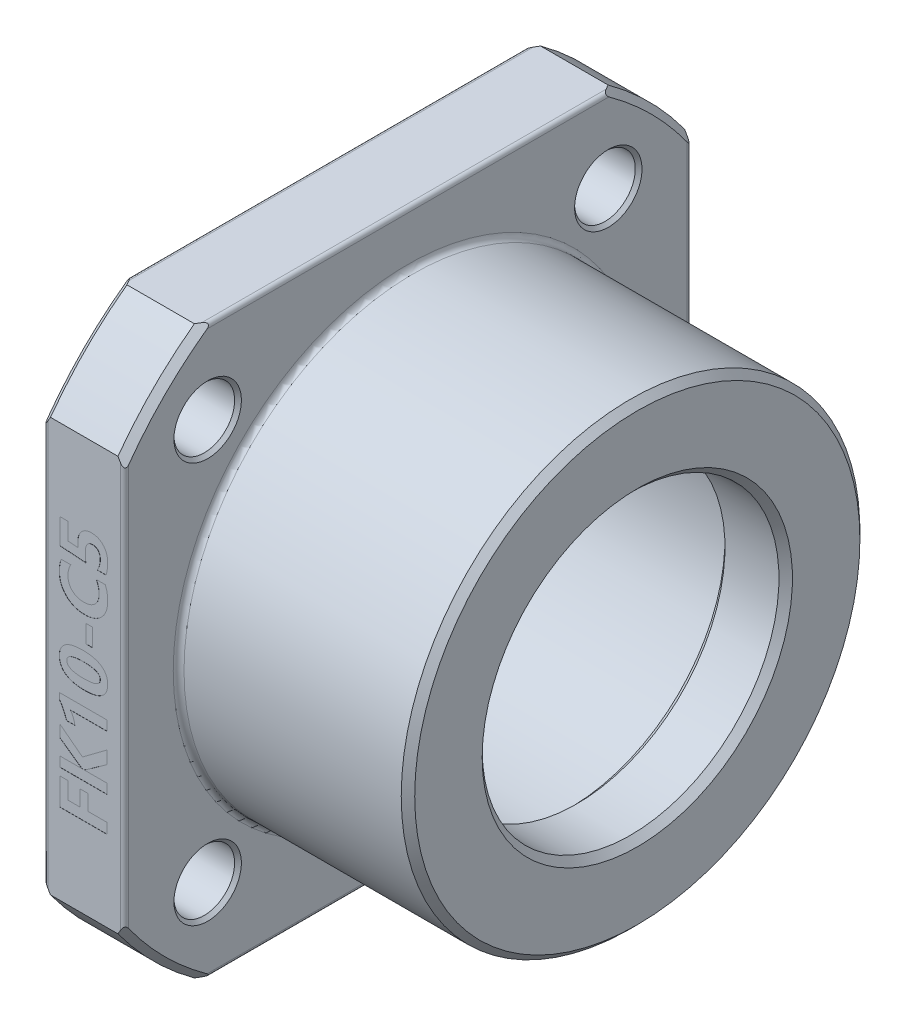
from build123d import *

# Parameters (mm, degrees)
CUT_EXTRUDE_1_REACH              = 25
HOLE_WIZARD_4_5_4_5_1_AT_2_COUNT = 2
HOLE_WIZARD_4_5_4_5_1_AT_2_PITCH = 29.69848481
HOLE_WIZARD_4_5_4_5_1_AT_3_COUNT = 2
HOLE_WIZARD_4_5_4_5_1_AT_3_PITCH = 42
HOLE_WIZARD_4_5_4_5_1_AT_4_COUNT = 2
HOLE_WIZARD_4_5_4_5_1_AT_4_PITCH = 29.69848481
M4X0_71_D                        = 3.3
M4X0_71_DEPTH                    = 5
M4X0_71_CSINK_D                  = 4.2
M4X0_71_CSINK_ANGLE              = 90
M4X0_71_TIP                      = 0.991420021
FILLET_1_R                       = 0.3
SKETCH_7_W                       = 0.512195122
SKETCH_7_H                       = 1.323170731
CUT_EXTRUDE_2_DEPTH              = 0.01


with BuildPart() as part:
    # Эскиз1 → Повернуть1 (revolve)
    with BuildSketch(Plane.XY):
        with BuildLine():
            Line((22.5, 11), (18.5, 11))
            Line((18.5, 11), (18, 11.5))
            Line((18, 11.5), (18, 12.6))
            ThreePointArc((18, 12.6), (17.882842712, 12.882842712), (17.6, 13))
            Line((17.6, 13), (0.5, 13))
            Line((0.5, 13), (0, 13.5))
            Line((0, 13.5), (0, 25.5))
            Line((0, 25.5), (0.5, 26))
            Line((0.5, 26), (5.5, 26))
            Line((5.5, 26), (6, 25.5))
            Line((6, 25.5), (6, 17.4))
            ThreePointArc((6, 17.4), (6.117157288, 17.117157288), (6.4, 17))
            Line((6.4, 17), (22.5, 17))
            Line((22.5, 17), (23, 16.5))
            Line((23, 16.5), (23, 11.5))
            Line((23, 11.5), (22.5, 11))
        make_face()
    revolve(axis=Axis((0, 0, 0), (1, 0, 0)))

    # Эскиз2 → Вырез-Вытянуть1 (cut, up to next)
    with BuildSketch(Plane.ZY, mode=Mode.PRIVATE) as cut_extrude_1_sk1:
        with BuildLine():
            Line((-15.329709717, 21), (15.329709717, 21))
            ThreePointArc((15.329709717, 21), (0, 26), (-15.329709717, 21))
        make_face()
    cut_extrude_1_tool1 = extrude(cut_extrude_1_sk1.sketch, amount=-CUT_EXTRUDE_1_REACH, mode=Mode.PRIVATE) & part.part
    add(cut_extrude_1_tool1.solids().sort_by_distance((0, 23.017458, 0))[0], mode=Mode.SUBTRACT)
    # Эскиз2 → Вырез-Вытянуть1 (cut, up to next)
    with BuildSketch(Plane.ZY, mode=Mode.PRIVATE) as cut_extrude_1_sk2:
        with BuildLine():
            Line((21, 15.329709717), (21, -15.329709717))
            ThreePointArc((21, -15.329709717), (26, 0), (21, 15.329709717))
        make_face()
    cut_extrude_1_tool2 = extrude(cut_extrude_1_sk2.sketch, amount=-CUT_EXTRUDE_1_REACH, mode=Mode.PRIVATE) & part.part
    add(cut_extrude_1_tool2.solids().sort_by_distance((0, 0, 23.017458))[0], mode=Mode.SUBTRACT)
    # Эскиз2 → Вырез-Вытянуть1 (cut, up to next)
    with BuildSketch(Plane.ZY, mode=Mode.PRIVATE) as cut_extrude_1_sk3:
        with BuildLine():
            Line((15.329709717, -21), (-15.329709717, -21))
            ThreePointArc((-15.329709717, -21), (0, -26), (15.329709717, -21))
        make_face()
    cut_extrude_1_tool3 = extrude(cut_extrude_1_sk3.sketch, amount=-CUT_EXTRUDE_1_REACH, mode=Mode.PRIVATE) & part.part
    add(cut_extrude_1_tool3.solids().sort_by_distance((0, -23.017458, 0))[0], mode=Mode.SUBTRACT)
    # Эскиз2 → Вырез-Вытянуть1 (cut, up to next)
    with BuildSketch(Plane.ZY, mode=Mode.PRIVATE) as cut_extrude_1_sk4:
        with BuildLine():
            Line((-21, -15.329709717), (-21, 15.329709717))
            ThreePointArc((-21, 15.329709717), (-26, 0), (-21, -15.329709717))
        make_face()
    cut_extrude_1_tool4 = extrude(cut_extrude_1_sk4.sketch, amount=-CUT_EXTRUDE_1_REACH, mode=Mode.PRIVATE) & part.part
    add(cut_extrude_1_tool4.solids().sort_by_distance((0, 0, -23.017458))[0], mode=Mode.SUBTRACT)

    # Эскиз4 → Диаметр отверстия Ø4.5 (4.5)1 (revolve, cut)
    with BuildSketch(Plane(origin=(0, 14.849242405, -14.849242405), x_dir=(0, 0, 1), z_dir=(0, 1, 0))):
        Polygon((0, 0), (0, 6), (2.5, 6), (2.25, 5.75), (2.25, 0.25), (2.5, 0), align=None)
    hole_wizard_4_5_4_5_1 = revolve(axis=Axis((-6.35, 14.849242405, -14.849242405), (1, 0, 0)), mode=Mode.SUBTRACT)

    # Диаметр отверстия Ø4.5 (4.5)1 at 2: Диаметр отверстия Ø4.5 (4.5)1 ×2
    with Locations(*[(0, 0, i * HOLE_WIZARD_4_5_4_5_1_AT_2_PITCH) for i in range(1, HOLE_WIZARD_4_5_4_5_1_AT_2_COUNT)]):
        add(hole_wizard_4_5_4_5_1, mode=Mode.SUBTRACT)

    # Диаметр отверстия Ø4.5 (4.5)1 at 3: Диаметр отверстия Ø4.5 (4.5)1 ×2
    with Locations(*[Vector(0, -0.707106781, 0.707106781) * (i * HOLE_WIZARD_4_5_4_5_1_AT_3_PITCH) for i in range(1, HOLE_WIZARD_4_5_4_5_1_AT_3_COUNT)]):
        add(hole_wizard_4_5_4_5_1, mode=Mode.SUBTRACT)

    # Диаметр отверстия Ø4.5 (4.5)1 at 4: Диаметр отверстия Ø4.5 (4.5)1 ×2
    with Locations(*[(0, -i * HOLE_WIZARD_4_5_4_5_1_AT_4_PITCH, 0) for i in range(1, HOLE_WIZARD_4_5_4_5_1_AT_4_COUNT)]):
        add(hole_wizard_4_5_4_5_1, mode=Mode.SUBTRACT)

    # Отверстие обработанное метчиком M4x0.71
    with Locations(Plane.ZY):
        with Locations((5.814342437, 15.974774553), (-5.814342437, -15.974774553), (-15.974774553, 5.814342437), (15.974774553, -5.814342437)):
            CounterSinkHole(M4X0_71_D / 2, M4X0_71_CSINK_D / 2, depth=M4X0_71_DEPTH, counter_sink_angle=M4X0_71_CSINK_ANGLE)
            with Locations((0, 0, -(M4X0_71_DEPTH + M4X0_71_TIP / 2))):  # 118° drill point
                Cone(0, M4X0_71_D / 2, M4X0_71_TIP, mode=Mode.SUBTRACT)

    # Скругление1
    fillet_1_edges = [part.edges().sort_by_distance(p)[0] for p in [
        (0, -21, 0),
        (0, 0, 21),
        (6, 0, 21),
        (6, -21, 0),
        (6, 21, 0),
        (6, 0, -21),
        (0, 0, -21),
        (0, 21, 0),
    ]]
    fillet(fillet_1_edges, radius=FILLET_1_R)

    # Эскиз7 → Вырез-Вытянуть2 (cut)
    with BuildSketch(Plane.XY.offset(21)):
        Polygon((1.797560976, -7.341463415), (1.797560976, -8.597942073), (2.693902439, -8.597942073), (2.693902439, -7.426829268), (3.291463415, -7.426829268), (3.291463415, -8.579268293), (4.7, -8.579268293), (4.7, -9.347560976), (1.2, -9.347560976), (1.2, -7.341463415), align=None)
        with BuildLine():
            Line((4.7, -3.926829268), (4.7, -4.867854421))
            Line((4.7, -4.867854421), (3.170083841, -5.954935213))
            add(Edge.make_bspline(
                [(3.170083841, -5.954935213), (3.159067041, -5.962212696), (3.134927561, -5.978158764), (3.092935798, -6.000484352), (3.043214099, -6.025160618), (3.006764784, -6.041130504), (2.987347561, -6.049637957)],
                knots=[0, 0, 0, 0, 3.9591e-05, 8.6749e-05, 0.000142524, 0.000206109, 0.000206109, 0.000206109, 0.000206109], degree=3))
            Line((2.987347561, -6.049637957), (2.987347561, -6.06097561))
            Line((2.987347561, -6.06097561), (4.7, -6.06097561))
            Line((4.7, -6.06097561), (4.7, -6.786585366))
            Line((4.7, -6.786585366), (1.2, -6.786585366))
            Line((1.2, -6.786585366), (1.2, -6.06097561))
            Line((1.2, -6.06097561), (2.853963415, -6.06097561))
            Line((2.853963415, -6.06097561), (2.853963415, -6.049637957))
            add(Edge.make_bspline(
                [(2.853963415, -6.049637957), (2.819865524, -6.033081858), (2.755805667, -6.001977843), (2.694999054, -5.964927982), (2.666558689, -5.947599085)],
                knots=[0, 0, 0, 0, 0.000113637, 0.000213491, 0.000213491, 0.000213491, 0.000213491], degree=3))
            Line((2.666558689, -5.947599085), (1.2, -4.899199695))
            Line((1.2, -4.899199695), (1.2, -4.012195122))
            Line((1.2, -4.012195122), (2.869969512, -5.292016006))
            Line((2.869969512, -5.292016006), (4.7, -3.926829268))
        make_face()
        with BuildLine():
            Line((1.157317073, -2.006097561), (4.7, -2.006097561))
            Line((4.7, -2.006097561), (4.7, -2.731707317))
            Line((4.7, -2.731707317), (1.98363186, -2.731707317))
            add(Edge.make_bspline(
                [(1.98363186, -2.731707317), (2.003042958, -2.756240704), (2.043717491, -2.807648617), (2.097003307, -2.896035957), (2.148467939, -2.996205566), (2.194825293, -3.106422361), (2.235784187, -3.220082688), (2.270620271, -3.331241944), (2.294759203, -3.438415413), (2.304853464, -3.50859684), (2.309756098, -3.542682927)],
                knots=[0, 0, 0, 0, 9.3771e-05, 0.000196489, 0.000308938, 0.00043145, 0.000554867, 0.00067132, 0.000780695, 0.000883982, 0.000883982, 0.000883982, 0.000883982], degree=3))
            Line((2.309756098, -3.542682927), (1.686185213, -3.542682927))
            add(Edge.make_bspline(
                [(1.686185213, -3.542682927), (1.670655185, -3.491395543), (1.639919358, -3.389891538), (1.585994211, -3.24196246), (1.528441675, -3.098707539), (1.464103346, -2.961470472), (1.395200724, -2.829174362), (1.322352586, -2.701470035), (1.242598078, -2.579921881), (1.185664751, -2.502269225), (1.157317073, -2.463605183)],
                knots=[0, 0, 0, 0, 0.000160732, 0.000318108, 0.000472173, 0.000623744, 0.000772593, 0.00091959, 0.001064613, 0.001208428, 0.001208428, 0.001208428, 0.001208428], degree=3))
            Line((1.157317073, -2.463605183), (1.157317073, -2.006097561))
        make_face()
        with BuildLine():
            add(Edge.make_bspline(
                [(3.006021341, -0.93902439), (2.933303397, -0.937969873), (2.791922548, -0.935919642), (2.586510625, -0.920984943), (2.394343966, -0.894175423), (2.215550515, -0.857937607), (2.049529745, -0.811649254), (1.897215016, -0.753495211), (1.757457447, -0.685690089), (1.631512327, -0.606827156), (1.519437974, -0.518203338), (1.422463765, -0.419337787), (1.340326691, -0.311155622), (1.273126501, -0.193434262), (1.220885032, -0.066306245), (1.183538562, 0.070038389), (1.161281344, 0.21579385), (1.158661295, 0.316041189), (1.157317073, 0.367473323)],
                knots=[0, 0, 0, 0, 0.000218148, 0.000424132, 0.000617388, 0.000799848, 0.000971065, 0.001133817, 0.001288318, 0.00143635, 0.001578731, 0.00171597, 0.001850689, 0.001985111, 0.002121472, 0.002261914, 0.002408299, 0.002562533, 0.002562533, 0.002562533, 0.002562533], degree=3))
            add(Edge.make_bspline(
                [(1.157317073, 0.367473323), (1.158475399, 0.416456882), (1.160729419, 0.511775456), (1.181707069, 0.649860304), (1.21636127, 0.778649247), (1.265120108, 0.897911238), (1.327621409, 1.007983548), (1.404477274, 1.107926758), (1.494733144, 1.199024296), (1.599509378, 1.279647375), (1.718034797, 1.350699837), (1.850269371, 1.411514013), (1.995420177, 1.464781712), (2.15515485, 1.505777166), (2.328179516, 1.539183817), (2.515068014, 1.562811236), (2.71569492, 1.576776224), (2.853940055, 1.578419681), (2.925323933, 1.579268293)],
                knots=[0, 0, 0, 0, 0.000146874, 0.000285807, 0.000417825, 0.000546132, 0.00067129, 0.00079641, 0.000923267, 0.001054934, 0.001191957, 0.001336961, 0.001490975, 0.001655169, 0.001831091, 0.002019366, 0.002219931, 0.002434064, 0.002434064, 0.002434064, 0.002434064], degree=3))
            add(Edge.make_bspline(
                [(2.925323933, 1.579268293), (2.99582578, 1.578264611), (3.132779761, 1.576314899), (3.332052939, 1.560676507), (3.519051062, 1.535990429), (3.693863188, 1.500108862), (3.856234791, 1.453601199), (4.006314688, 1.397053198), (4.144107672, 1.33026788), (4.268977857, 1.253129032), (4.380566303, 1.166098449), (4.477940282, 1.069936187), (4.560435662, 0.964022933), (4.627507132, 0.848703156), (4.678818312, 0.723975063), (4.716625731, 0.590744122), (4.738654757, 0.448015171), (4.741318645, 0.349765111), (4.742682927, 0.299447409)],
                knots=[0, 0, 0, 0, 0.000211481, 0.000410815, 0.000599264, 0.000777017, 0.000945669, 0.001105453, 0.001257571, 0.001404332, 0.001544949, 0.001681238, 0.001813841, 0.00194653, 0.00208017, 0.002217401, 0.002361149, 0.002512052, 0.002512052, 0.002512052, 0.002512052], degree=3))
            add(Edge.make_bspline(
                [(4.742682927, 0.299447409), (4.741554848, 0.24934808), (4.739363535, 0.152029262), (4.718024308, 0.010988974), (4.684476082, -0.120481699), (4.636780452, -0.242355655), (4.575756325, -0.354864152), (4.500748101, -0.457526126), (4.411192385, -0.549792503), (4.308724825, -0.632748213), (4.192382752, -0.705621211), (4.062500877, -0.768282162), (3.919366334, -0.821531843), (3.762572892, -0.864359756), (3.592576863, -0.89846379), (3.408914828, -0.921653272), (3.211909555, -0.936774258), (3.076078111, -0.938258747), (3.006021341, -0.93902439)],
                knots=[0, 0, 0, 0, 0.000150205, 0.000291776, 0.000426846, 0.000556513, 0.000683351, 0.000809808, 0.000936686, 0.001068028, 0.001204397, 0.001347568, 0.001499935, 0.001661904, 0.001834683, 0.002019651, 0.002216939, 0.00242707, 0.00242707, 0.00242707, 0.00242707], degree=3))
        make_face()
        with BuildLine():
            add(Edge.make_bspline(
                [(2.988014482, -0.213414634), (3.036488003, -0.213141745), (3.130372233, -0.212613209), (3.266236741, -0.205422046), (3.392886367, -0.195984266), (3.510231402, -0.181550752), (3.618093153, -0.162090149), (3.716912859, -0.139741008), (3.806341599, -0.112946411), (3.886039156, -0.080377625), (3.957362299, -0.045864158), (4.01857953, -0.005478873), (4.070813281, 0.038881109), (4.114009108, 0.087542787), (4.147213243, 0.141082704), (4.170774787, 0.198531142), (4.185335034, 0.26026911), (4.1869678, 0.302922882), (4.187804878, 0.324790396)],
                knots=[0, 0, 0, 0, 0.000145402, 0.000281618, 0.000408062, 0.000526354, 0.000636112, 0.000736738, 0.000830195, 0.000915771, 0.000994809, 0.001067503, 0.001135139, 0.001199886, 0.001261884, 0.00132319, 0.001385475, 0.001451, 0.001451, 0.001451, 0.001451], degree=3))
            add(Edge.make_bspline(
                [(4.187804878, 0.324790396), (4.187007693, 0.346223199), (4.18544318, 0.38828609), (4.170159734, 0.448933045), (4.145751826, 0.505565017), (4.111369009, 0.557817794), (4.067119045, 0.605829155), (4.013114644, 0.649103092), (3.94986254, 0.688402614), (3.877332566, 0.723902627), (3.794719021, 0.754247686), (3.702500544, 0.780373993), (3.601188603, 0.804218225), (3.489825614, 0.821322886), (3.369089135, 0.83619046), (3.23849077, 0.846714871), (3.098333872, 0.852558208), (3.001803125, 0.853284056), (2.952000762, 0.853658537)],
                knots=[0, 0, 0, 0, 6.4194e-05, 0.000125984, 0.000186321, 0.000248474, 0.000312672, 0.000381416, 0.000455433, 0.000535666, 0.000623246, 0.000719069, 0.000823094, 0.000935258, 0.001056859, 0.00118801, 0.001328192, 0.001477596, 0.001477596, 0.001477596, 0.001477596], degree=3))
            add(Edge.make_bspline(
                [(2.952000762, 0.853658537), (2.901975207, 0.85329953), (2.804998316, 0.852603578), (2.664426363, 0.846558279), (2.533603552, 0.836805768), (2.412567914, 0.822823713), (2.300912689, 0.805317046), (2.1990605, 0.782471871), (2.106611494, 0.756961643), (2.024067227, 0.726907326), (1.950729471, 0.693161308), (1.887258937, 0.654800371), (1.833596862, 0.612083905), (1.78863546, 0.566125763), (1.754318269, 0.514912361), (1.729835269, 0.459650735), (1.714613933, 0.400522766), (1.713008822, 0.359561017), (1.712195122, 0.338795732)],
                knots=[0, 0, 0, 0, 0.000150071, 0.000290919, 0.000422017, 0.00054354, 0.000656362, 0.00076089, 0.00085653, 0.000943878, 0.001024136, 0.001098369, 0.001165757, 0.001229437, 0.001290477, 0.001349593, 0.001410088, 0.001472287, 0.001472287, 0.001472287, 0.001472287], degree=3))
            add(Edge.make_bspline(
                [(1.712195122, 0.338795732), (1.712927618, 0.316461423), (1.714367242, 0.272566309), (1.73062219, 0.209384557), (1.755255361, 0.149964349), (1.791564268, 0.095766773), (1.836598786, 0.045128901), (1.892130767, -0.000373856), (1.957619496, -0.040980018), (2.032804564, -0.077514785), (2.1177884, -0.110122773), (2.212850503, -0.137904917), (2.317882261, -0.16088842), (2.432753862, -0.180028432), (2.557563848, -0.195417354), (2.692213275, -0.205546387), (2.836770867, -0.212585558), (2.936429899, -0.213131862), (2.988014482, -0.213414634)],
                knots=[0, 0, 0, 0, 6.6855e-05, 0.000131395, 0.000194446, 0.000259004, 0.000326075, 0.00039712, 0.00047354, 0.000556755, 0.00064754, 0.000746298, 0.000853575, 0.000969904, 0.001095558, 0.001230698, 0.001374907, 0.001529646, 0.001529646, 0.001529646, 0.001529646], degree=3))
        make_face(mode=Mode.SUBTRACT)
        with Locations((3.376829268, 2.753048781)):
            Rectangle(SKETCH_7_W, SKETCH_7_H)
        with BuildLine():
            add(Edge.make_bspline(
                [(4.559279726, 6.615853659), (4.574001487, 6.583375896), (4.60411557, 6.516941043), (4.640836246, 6.411036098), (4.673172336, 6.298521777), (4.698100145, 6.178264686), (4.717936325, 6.051154391), (4.732584039, 5.916978516), (4.741400219, 5.775653487), (4.742247791, 5.67906542), (4.742682927, 5.629477896)],
                knots=[0, 0, 0, 0, 0.000106926, 0.000218722, 0.00033589, 0.000457929, 0.000586873, 0.000721724, 0.000862711, 0.001011459, 0.001011459, 0.001011459, 0.001011459], degree=3))
            add(Edge.make_bspline(
                [(4.742682927, 5.629477896), (4.741339735, 5.565833013), (4.738715344, 5.441480672), (4.716355558, 5.260213454), (4.679760722, 5.08895003), (4.628727329, 4.927615656), (4.561923218, 4.776606688), (4.482155575, 4.634807616), (4.385752871, 4.504139586), (4.275955274, 4.384324538), (4.153794046, 4.276862794), (4.021099652, 4.18319189), (3.878937391, 4.103172442), (3.726596135, 4.038294859), (3.564421973, 3.988545241), (3.392812189, 3.952486554), (3.211534519, 3.931007144), (3.087444109, 3.928242254), (3.024028201, 3.926829268)],
                knots=[0, 0, 0, 0, 0.00019088, 0.000372951, 0.000546927, 0.000715659, 0.000879599, 0.001041485, 0.001202756, 0.001365606, 0.001528163, 0.001689888, 0.001852026, 0.00201666, 0.002185628, 0.002360117, 0.002542108, 0.002732322, 0.002732322, 0.002732322, 0.002732322], degree=3))
            add(Edge.make_bspline(
                [(3.024028201, 3.926829268), (2.957037013, 3.928292672), (2.825721057, 3.931161233), (2.633549369, 3.955840713), (2.450447634, 3.99529151), (2.277058282, 4.052508363), (2.112631828, 4.124610221), (1.95750049, 4.213064944), (1.812470776, 4.318540945), (1.677536026, 4.438223422), (1.554886465, 4.570200228), (1.448578387, 4.71354492), (1.358293748, 4.866138942), (1.285055664, 5.028190961), (1.227124199, 5.199217801), (1.186953031, 5.379879462), (1.161506538, 5.569616658), (1.15873075, 5.69942158), (1.157317073, 5.765529726)],
                knots=[0, 0, 0, 0, 0.000200903, 0.000393809, 0.000580224, 0.00076202, 0.000940587, 0.001118024, 0.001296652, 0.001477594, 0.001658349, 0.001836152, 0.002011953, 0.002189238, 0.002368714, 0.002552671, 0.002743677, 0.002941914, 0.002941914, 0.002941914, 0.002941914], degree=3))
            add(Edge.make_bspline(
                [(1.157317073, 5.765529726), (1.157593626, 5.807113823), (1.158133804, 5.88833796), (1.165495285, 6.007515549), (1.17483644, 6.121739082), (1.189699543, 6.230730255), (1.208033735, 6.334791588), (1.231813946, 6.433175843), (1.257653126, 6.527095811), (1.279827064, 6.586648749), (1.29070122, 6.615853659)],
                knots=[0, 0, 0, 0, 0.00012473, 0.000243629, 0.000358111, 0.000468465, 0.000573511, 0.000674938, 0.000772043, 0.000865491, 0.000865491, 0.000865491, 0.000865491], degree=3))
            Line((1.29070122, 6.615853659), (2.01097561, 6.615853659))
            add(Edge.make_bspline(
                [(2.01097561, 6.615853659), (1.993840459, 6.586311043), (1.959582877, 6.527247745), (1.916448676, 6.434089213), (1.879883253, 6.338207307), (1.849581454, 6.23955243), (1.826251932, 6.137908564), (1.809752561, 6.033174868), (1.799426249, 5.925576098), (1.798187004, 5.852919564), (1.797560976, 5.816215701)],
                knots=[0, 0, 0, 0, 0.000102413, 0.00020475, 0.000307553, 0.000410081, 0.000514106, 0.000620132, 0.000727971, 0.000838063, 0.000838063, 0.000838063, 0.000838063], degree=3))
            add(Edge.make_bspline(
                [(1.797560976, 5.816215701), (1.798657965, 5.77482424), (1.800805926, 5.693777702), (1.815510493, 5.575153996), (1.840427254, 5.462812706), (1.87707926, 5.357381595), (1.922434628, 5.25796905), (1.977920789, 5.16461426), (2.044474979, 5.078263053), (2.120506763, 4.99916053), (2.204426133, 4.927709639), (2.295566283, 4.865662977), (2.392702876, 4.81225739), (2.496671985, 4.770299576), (2.605852741, 4.735204459), (2.721887619, 4.713012973), (2.843754701, 4.697352792), (2.927270621, 4.695877098), (2.970007622, 4.695121951)],
                knots=[0, 0, 0, 0, 0.000124162, 0.000243115, 0.000357988, 0.000468715, 0.000577339, 0.000685311, 0.000793759, 0.000903663, 0.001013907, 0.001123787, 0.001233912, 0.00134575, 0.001459655, 0.001577369, 0.001699633, 0.001827766, 0.001827766, 0.001827766, 0.001827766], degree=3))
            add(Edge.make_bspline(
                [(2.970007622, 4.695121951), (3.011615467, 4.696029173), (3.092829016, 4.697799961), (3.211541862, 4.711299224), (3.323904377, 4.733659709), (3.429878106, 4.765943543), (3.529744313, 4.806680656), (3.623774111, 4.85617952), (3.711534094, 4.915053782), (3.792187459, 4.983114732), (3.864755078, 5.059005578), (3.928382552, 5.14152223), (3.983410508, 5.22997409), (4.026087053, 5.325939136), (4.060690782, 5.427660398), (4.085023799, 5.535835528), (4.100063108, 5.650393998), (4.101635565, 5.728801406), (4.102439024, 5.768864329)],
                knots=[0, 0, 0, 0, 0.000124802, 0.000243598, 0.000357912, 0.000468041, 0.000575417, 0.000681027, 0.000786275, 0.00089182, 0.000997009, 0.001100659, 0.001203946, 0.001308706, 0.001414999, 0.001525823, 0.001640806, 0.001760943, 0.001760943, 0.001760943, 0.001760943], degree=3))
            add(Edge.make_bspline(
                [(4.102439024, 5.768864329), (4.101802503, 5.807122413), (4.100538369, 5.883103131), (4.090311387, 5.995594007), (4.073613136, 6.105618237), (4.050315061, 6.213011197), (4.020283189, 6.317962419), (3.983437898, 6.420176183), (3.940333939, 6.519957381), (3.906151617, 6.583843296), (3.88902439, 6.615853659)],
                knots=[0, 0, 0, 0, 0.000114759, 0.000227912, 0.00033855, 0.000448432, 0.000557355, 0.000665786, 0.000774202, 0.000883075, 0.000883075, 0.000883075, 0.000883075], degree=3))
            Line((3.88902439, 6.615853659), (4.559279726, 6.615853659))
        make_face()
        with BuildLine():
            Line((4.614634146, 7.256097561), (3.967054116, 7.256097561))
            add(Edge.make_bspline(
                [(3.967054116, 7.256097561), (3.984850987, 7.286754351), (4.020078436, 7.347436958), (4.06459087, 7.442180904), (4.102877748, 7.538051833), (4.133442479, 7.635793079), (4.157614689, 7.734692463), (4.174814, 7.834964918), (4.186109831, 7.936764635), (4.187237128, 8.005241715), (4.187804878, 8.039729421)],
                knots=[0, 0, 0, 0, 0.0001063, 0.000210412, 0.000313699, 0.000415788, 0.00051737, 0.0006189, 0.000720832, 0.000824259, 0.000824259, 0.000824259, 0.000824259], degree=3))
            add(Edge.make_bspline(
                [(4.187804878, 8.039729421), (4.187190526, 8.065083426), (4.185992027, 8.114544925), (4.179636642, 8.186843601), (4.167586747, 8.254842976), (4.151022256, 8.318471229), (4.129598264, 8.377986766), (4.102855116, 8.432954009), (4.072336383, 8.484416507), (4.035996719, 8.530343124), (3.996094195, 8.571519827), (3.95310346, 8.608250649), (3.90612483, 8.638844256), (3.855949898, 8.664468526), (3.802368061, 8.683841073), (3.745445348, 8.696869087), (3.685468627, 8.706106253), (3.644079358, 8.706907508), (3.622923018, 8.707317073)],
                knots=[0, 0, 0, 0, 7.6076e-05, 0.000148411, 0.000217488, 0.000283003, 0.000345452, 0.000406899, 0.000466146, 0.000524581, 0.000582122, 0.000637968, 0.00069383, 0.000749903, 0.000806654, 0.000864242, 0.000924888, 0.000988301, 0.000988301, 0.000988301, 0.000988301], degree=3))
            add(Edge.make_bspline(
                [(3.622923018, 8.707317073), (3.60086905, 8.706984291), (3.558101448, 8.706338951), (3.496113792, 8.696182533), (3.438142825, 8.682298737), (3.384530532, 8.660993442), (3.335011205, 8.634529038), (3.289839636, 8.601565281), (3.249567473, 8.562062862), (3.212643741, 8.517427291), (3.180546849, 8.46625081), (3.153483339, 8.409193199), (3.129919611, 8.346547163), (3.110790801, 8.278043474), (3.096242586, 8.203301329), (3.085891665, 8.122879906), (3.078902962, 8.036517184), (3.078339579, 7.977053553), (3.07804878, 7.946360518)],
                knots=[0, 0, 0, 0, 6.6079e-05, 0.000128142, 0.000187991, 0.000244589, 0.000300689, 0.000356048, 0.000411703, 0.000469513, 0.000529462, 0.000592401, 0.000658671, 0.000730035, 0.000805503, 0.000886903, 0.000973194, 0.001065251, 0.001065251, 0.001065251, 0.001065251], degree=3))
            add(Edge.make_bspline(
                [(3.07804878, 7.946360518), (3.078594699, 7.897665056), (3.079724597, 7.796879142), (3.088344467, 7.640319757), (3.101502612, 7.473072532), (3.114186549, 7.358105644), (3.120731707, 7.298780488)],
                knots=[0, 0, 0, 0, 0.00014608, 0.000302345, 0.000470272, 0.000649317, 0.000649317, 0.000649317, 0.000649317], degree=3))
            Line((3.120731707, 7.298780488), (1.2, 7.431497713))
            Line((1.2, 7.431497713), (1.2, 9.304878049))
            Line((1.2, 9.304878049), (1.797560976, 9.304878049))
            Line((1.797560976, 9.304878049), (1.797560976, 8.031726372))
            Line((1.797560976, 8.031726372), (2.539176829, 7.981707317))
            add(Edge.make_bspline(
                [(2.539176829, 7.981707317), (2.534511014, 8.041700018), (2.525567803, 8.156691166), (2.52394628, 8.27201479), (2.523170732, 8.327172256)],
                knots=[0, 0, 0, 0, 0.000180468, 0.000345913, 0.000345913, 0.000345913, 0.000345913], degree=3))
            add(Edge.make_bspline(
                [(2.523170732, 8.327172256), (2.524153947, 8.368771022), (2.526072491, 8.449942509), (2.538480826, 8.568497095), (2.560692033, 8.679938241), (2.590416706, 8.78513423), (2.629935485, 8.883056383), (2.677483889, 8.974961816), (2.734326557, 9.059525759), (2.79906581, 9.137430143), (2.871981842, 9.206477281), (2.950625125, 9.267811224), (3.036469449, 9.318663682), (3.12773758, 9.360919262), (3.225676887, 9.392846229), (3.329461193, 9.416205861), (3.439574907, 9.430357421), (3.515062329, 9.432058981), (3.553563262, 9.432926829)],
                knots=[0, 0, 0, 0, 0.000124802, 0.000243525, 0.000357054, 0.000465336, 0.000570975, 0.000673292, 0.000775211, 0.000876058, 0.000976533, 0.001075913, 0.001174619, 0.001275185, 0.001377049, 0.001483025, 0.001593954, 0.001709426, 0.001709426, 0.001709426, 0.001709426], degree=3))
            add(Edge.make_bspline(
                [(3.553563262, 9.432926829), (3.596313644, 9.432074083), (3.680183998, 9.430401113), (3.802726318, 9.412169979), (3.919497948, 9.384580273), (4.030254796, 9.345044012), (4.134694858, 9.293922448), (4.233757073, 9.232397237), (4.325739806, 9.158307781), (4.411903413, 9.074453198), (4.48955413, 8.980833741), (4.557574125, 8.878482582), (4.614898177, 8.768215306), (4.661769705, 8.649719734), (4.698442385, 8.523351755), (4.724189012, 8.388726118), (4.739634763, 8.246169384), (4.7416502, 8.148476895), (4.742682927, 8.098418445)],
                knots=[0, 0, 0, 0, 0.00012816, 0.000251432, 0.000370809, 0.000487674, 0.000603404, 0.000719058, 0.000836754, 0.000957017, 0.001079211, 0.001200921, 0.001325013, 0.001451335, 0.001582611, 0.001719162, 0.001862042, 0.002012194, 0.002012194, 0.002012194, 0.002012194], degree=3))
            add(Edge.make_bspline(
                [(4.742682927, 8.098418445), (4.742313483, 8.057728656), (4.741588312, 7.977859649), (4.735458368, 7.860400832), (4.725572577, 7.747599908), (4.711690573, 7.639666069), (4.693720663, 7.536613855), (4.671670818, 7.438477665), (4.646153587, 7.345017771), (4.624995232, 7.285327457), (4.614634146, 7.256097561)],
                knots=[0, 0, 0, 0, 0.000122063, 0.000239594, 0.000352747, 0.000461692, 0.000565964, 0.000666442, 0.000763366, 0.000856374, 0.000856374, 0.000856374, 0.000856374], degree=3))
        make_face()
    extrude(amount=-CUT_EXTRUDE_2_DEPTH, mode=Mode.SUBTRACT)


solid = part.part
